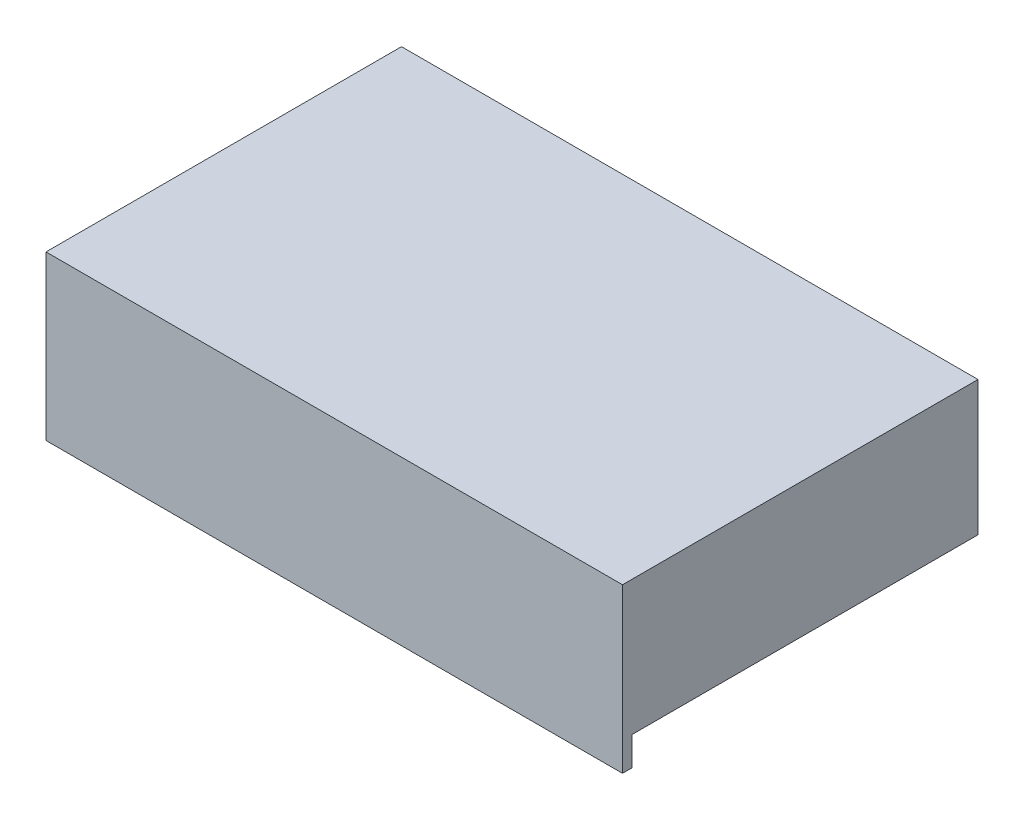
from build123d import *

# Parameters (mm, degrees)
SKETCH1_W                = 762
SKETCH1_H                = 457.2
BOSS_EXTRUDE1_DEPTH      = 177.8
SKETCH2_W                = 749.3
SKETCH2_H                = 444.5
CUT_EXTRUDE1_DEPTH       = 171.45
SKETCH4_W                = 758.825
SKETCH4_H                = 454.025
SKETCH4_W_2              = 752.475
SKETCH4_H_2              = 447.675
CUT_EXTRUDE3_DEPTH       = 3.175
SKETCH5_W                = 762
SKETCH5_H                = 12.7
BOSS_EXTRUDE2_DEPTH      = 177.8
BOSS_EXTRUDE2_DEPTH_BACK = 38.1
SKETCH7_R                = 6.35
BOSS_EXTRUDE3_DEPTH      = 762
SKETCH8_W                = 12.7
SKETCH8_H                = 38.1
CUT_EXTRUDE4_DEPTH       = 202.692


with BuildPart() as part:
    # Sketch1 → Boss-Extrude1 (new body)
    with BuildSketch(Plane(origin=(0, 0, 0), x_dir=(1, 0, 0), z_dir=(0, 1, 0))):
        Rectangle(SKETCH1_W, SKETCH1_H)
    extrude(amount=BOSS_EXTRUDE1_DEPTH)

    # Sketch2 → Cut-Extrude1 (cut)
    with BuildSketch(Plane.XZ):
        Rectangle(SKETCH2_W, SKETCH2_H)
    extrude(amount=-CUT_EXTRUDE1_DEPTH, mode=Mode.SUBTRACT)

    # Sketch4 → Cut-Extrude3 (cut)
    with BuildSketch(Plane.XZ):
        Rectangle(SKETCH4_W, SKETCH4_H)
        Rectangle(SKETCH4_W_2, SKETCH4_H_2, mode=Mode.SUBTRACT)
    extrude(amount=-CUT_EXTRUDE3_DEPTH, mode=Mode.SUBTRACT)

    # Sketch5 → Boss-Extrude2 (add, two sides)
    with BuildSketch(Plane(origin=(0, 0, 0), x_dir=(1, 0, 0), z_dir=(0, 1, 0))) as boss_extrude2_sk:
        with Locations((0, -234.95)):
            Rectangle(SKETCH5_W, SKETCH5_H)
    extrude(amount=BOSS_EXTRUDE2_DEPTH)
    extrude(boss_extrude2_sk.sketch, amount=-BOSS_EXTRUDE2_DEPTH_BACK)

    # Sketch7 → Boss-Extrude3 (add)
    with BuildSketch(Plane.ZY.offset(381)):
        with BuildLine():
            Line((-238.125, 9.525), (-238.125, 47.625))
            Line((-238.125, 47.625), (-228.6, 47.625))
            Line((-228.6, 47.625), (-228.6, 0))
            ThreePointArc((-228.6, 0), (-244.860192091, -6.735192091), (-238.125, 9.525))
        make_face()
        with Locations((-238.125, 0)):
            Circle(SKETCH7_R, mode=Mode.SUBTRACT)
    extrude(amount=-BOSS_EXTRUDE3_DEPTH)

    # Sketch8 → Cut-Extrude4 (cut)
    with BuildSketch(Plane(origin=(0, 177.8, 0), x_dir=(1, 0, 0), z_dir=(0, 1, 0))):
        Polygon((-120.65, 266.7), (-133.35, 266.7), (-133.35, 228.6), (-120.65, 228.6), (120.65, 228.6), (133.35, 228.6), (133.35, 266.7), (120.65, 266.7), align=None)
        with Locations((-152.4, 247.65)):
            Rectangle(SKETCH8_W, SKETCH8_H)
        Polygon((-247.65, 228.6), (-260.35, 228.6), (-381, 228.6), (-381, 266.7), (-260.35, 266.7), (-247.65, 266.7), align=None)
        with Locations((-177.8, 247.65)):
            Rectangle(SKETCH8_W, SKETCH8_H)
        with Locations((-228.6, 247.65)):
            Rectangle(SKETCH8_W, SKETCH8_H)
        with Locations((-203.2, 247.65)):
            Rectangle(SKETCH8_W, SKETCH8_H)
        with Locations((152.4, 247.65)):
            Rectangle(SKETCH8_W, SKETCH8_H)
        with Locations((177.8, 247.65)):
            Rectangle(SKETCH8_W, SKETCH8_H)
        with Locations((203.2, 247.65)):
            Rectangle(SKETCH8_W, SKETCH8_H)
        with Locations((228.6, 247.65)):
            Rectangle(SKETCH8_W, SKETCH8_H)
        Polygon((247.65, 266.7), (247.65, 228.6), (260.35, 228.6), (381, 228.6), (381, 266.7), (260.35, 266.7), align=None)
    extrude(amount=-CUT_EXTRUDE4_DEPTH, mode=Mode.SUBTRACT)


solid = part.part
